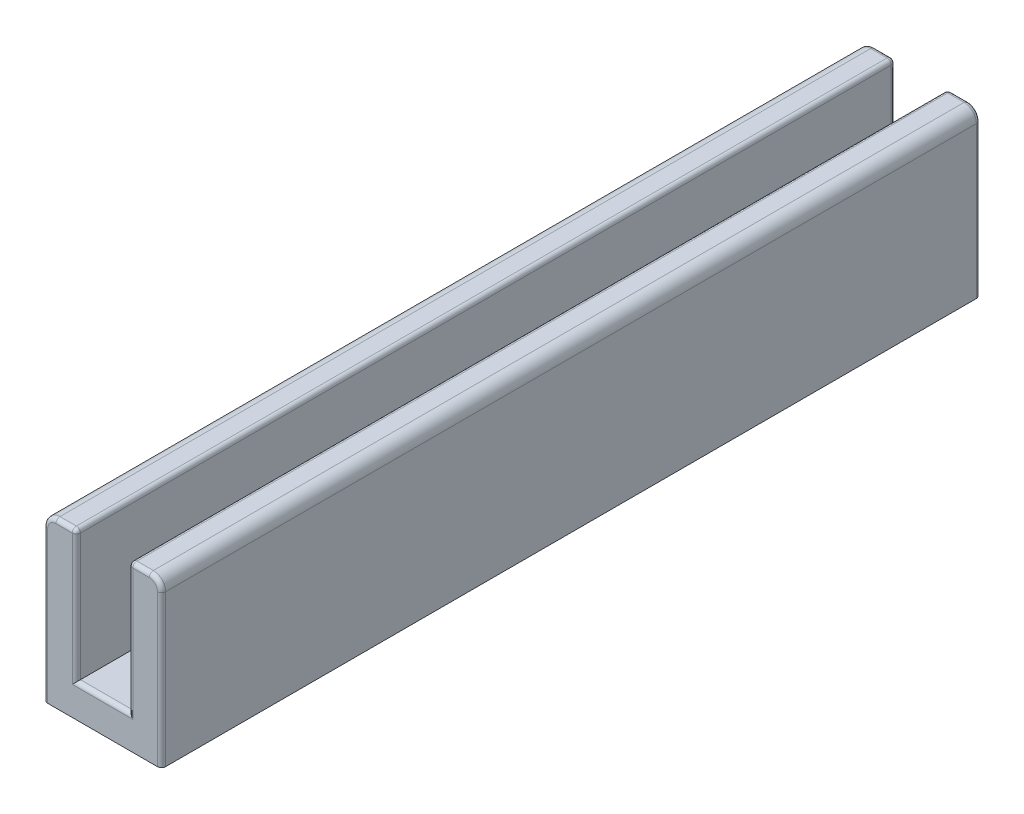
from build123d import *

# Parameters (mm, degrees)
BOSS_EXTRU_1_DEPTH = 50
CONG_1_R           = 0.75
CONG_2_R           = 0.25
CONG_3_R           = 0.25


with BuildPart() as part:
    # Esquisse1 → Boss.-Extru.1 (new body)
    with BuildSketch(Plane.XY):
        Polygon((3.2, 0), (0, 0), (0, 8), (-2, 8), (-2, 0), (-2, -2), (5.2, -2), (5.2, 0), (5.2, 8), (3.2, 8), align=None)
    extrude(amount=BOSS_EXTRU_1_DEPTH)

    # Congé1
    cong_1_edges = [part.edges().sort_by_distance(p)[0] for p in [
        (5.2, 8, 25),
        (-2, 8, 25),
    ]]
    fillet(cong_1_edges, radius=CONG_1_R)

    # Congé2
    cong_2_edges = [part.edges().sort_by_distance(p)[0] for p in [
        (3.2, 8, 25),
        (0, 8, 25),
    ]]
    fillet(cong_2_edges, radius=CONG_2_R)

    # Congé3
    cong_3_edges = [part.edges().sort_by_distance(p)[0] for p in [
        (1.6, 0, 0),
        (5.2, 2.625, 0),
        (0, 3.875, 0),
        (5.2, 2.625, 50),
        (-2, 2.625, 0),
        (-2, 2.625, 50),
        (3.95, 8, 0),
        (4.980330086, 7.780330086, 0),
        (-1.780330086, 7.780330086, 0),
        (3.95, 8, 50),
        (4.980330086, 7.780330086, 50),
        (-1.780330086, 7.780330086, 50),
        (1.6, 0, 50),
        (-0.75, 8, 0),
        (-0.75, 8, 50),
        (3.2, 3.875, 0),
        (3.273223305, 7.926776695, 0),
        (-0.073223305, 7.926776695, 0),
        (3.2, 3.875, 50),
        (3.273223305, 7.926776695, 50),
        (-0.073223305, 7.926776695, 50),
        (0, 3.875, 50),
    ]]
    fillet(cong_3_edges, radius=CONG_3_R)


solid = part.part
